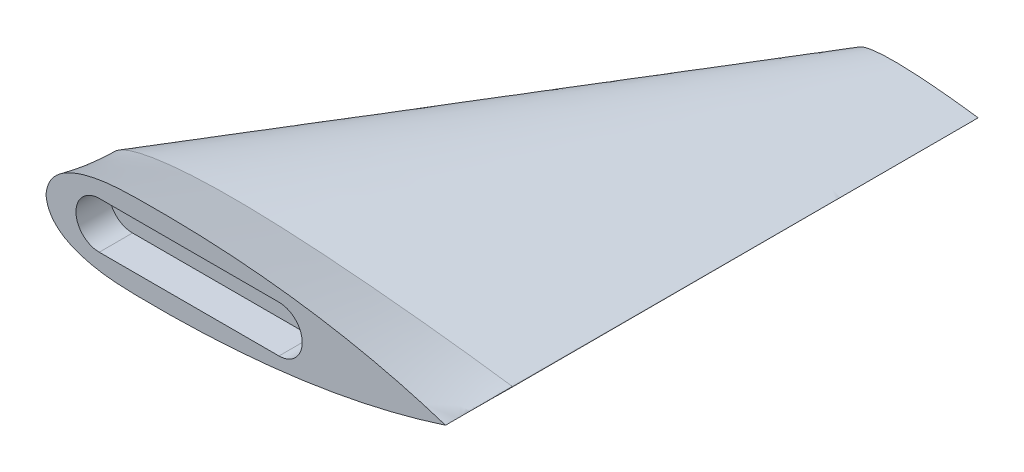
from build123d import *

# Parameters (mm, degrees)
CUT_EXTRUDE1_DEPTH = 5


with BuildPart() as part:
    # Sketch3 → Loft1 section 0
    with BuildSketch(Plane.XY.offset(70)):
        with BuildLine():
            add(Edge.make_bspline(
                [(42.022876489, 0), (42.022876489, -0.025878497), (42.030292538, -0.078965607), (42.063554444, -0.155915402), (42.117908781, -0.22997435), (42.19269573, -0.301463886), (42.287673315, -0.37063511), (42.402703243, -0.437554112), (42.537617166, -0.502144861), (42.69217588, -0.564260941), (42.866072758, -0.623717465), (43.058936641, -0.68031524), (43.270343068, -0.733841033), (43.49981216, -0.784100531), (43.74682173, -0.830887268), (44.010800762, -0.874031015), (44.291140004, -0.913354711), (44.587187402, -0.948725601), (44.898254935, -0.980017341), (45.223617257, -1.007142862), (45.562516237, -1.030039418), (45.914162375, -1.048668566), (46.27773462, -1.06303447), (46.652384122, -1.073163985), (47.037236556, -1.079112462), (47.43139403, -1.080971986), (47.833935949, -1.078853752), (48.243922409, -1.07289628), (48.660396106, -1.063260995), (49.082385456, -1.050131052), (49.508904835, -1.033698226), (49.938957981, -1.01417393), (50.371540867, -0.99177977), (50.805643888, -0.966741353), (51.240253368, -0.93929129), (51.674354334, -0.909662993), (52.106933472, -0.878089086), (52.53698035, -0.844806242), (52.963490882, -0.81003717), (53.38546826, -0.774008998), (53.801928512, -0.736940084), (54.211897782, -0.699043587), (54.614419588, -0.660532173), (55.008552494, -0.621601817), (55.393377825, -0.582454731), (55.767995156, -0.543281249), (56.131530502, -0.504273993), (56.48313406, -0.465622723), (56.821984355, -0.427500623), (57.147291331, -0.390101403), (57.458294583, -0.353598981), (57.754267715, -0.318172697), (58.034518631, -0.283997105), (58.298393967, -0.25125135), (58.54527673, -0.220100521), (58.77459078, -0.190718852), (58.9857996, -0.163257461), (59.178410588, -0.137883615), (59.351975669, -0.114738335), (59.506082658, -0.093952342), (59.640393607, -0.075694011), (59.754528952, -0.059944097), (59.848410148, -0.047189767), (59.921315664, -0.036471248), (59.974295109, -0.030390073), (60.004730475, -0.023809382), (60.035948769, -0.024404103), (60.035948769, 0.024404103), (60.004730475, 0.023809382), (59.974295109, 0.030390073), (59.921315664, 0.036471248), (59.848410148, 0.047189767), (59.754528952, 0.059944097), (59.640393607, 0.075694011), (59.506082658, 0.093952342), (59.351975669, 0.114738335), (59.178410588, 0.137883615), (58.9857996, 0.163257461), (58.77459078, 0.190718852), (58.54527673, 0.220100521), (58.298393967, 0.25125135), (58.034518631, 0.283997105), (57.754267715, 0.318172697), (57.458294583, 0.353598981), (57.147291331, 0.390101403), (56.821984355, 0.427500623), (56.48313406, 0.465622723), (56.131530502, 0.504273993), (55.767995156, 0.543281249), (55.393377825, 0.582454731), (55.008552494, 0.621601817), (54.614419588, 0.660532173), (54.211897782, 0.699043587), (53.801928512, 0.736940084), (53.38546826, 0.774008998), (52.963490882, 0.81003717), (52.53698035, 0.844806242), (52.106933472, 0.878089086), (51.674354334, 0.909662993), (51.240253368, 0.93929129), (50.805643888, 0.966741353), (50.371540867, 0.99177977), (49.938957981, 1.01417393), (49.508904835, 1.033698226), (49.082385456, 1.050131052), (48.660396106, 1.063260995), (48.243922409, 1.07289628), (47.833935949, 1.078853752), (47.43139403, 1.080971986), (47.037236556, 1.079112462), (46.652384122, 1.073163985), (46.27773462, 1.06303447), (45.914162375, 1.048668566), (45.562516237, 1.030039418), (45.223617257, 1.007142862), (44.898254935, 0.980017341), (44.587187402, 0.948725601), (44.291140004, 0.913354711), (44.010800762, 0.874031015), (43.74682173, 0.830887268), (43.49981216, 0.784100531), (43.270343068, 0.733841033), (43.058936641, 0.68031524), (42.866072758, 0.623717465), (42.69217588, 0.564260941), (42.537617166, 0.502144861), (42.402703243, 0.437554112), (42.287673315, 0.37063511), (42.19269573, 0.301463886), (42.117908781, 0.22997435), (42.063554444, 0.155915402), (42.030292538, 0.078965607), (42.022876489, 0.025878497), (42.022876489, 0)],
                knots=[0, 0, 0, 0, 0.002106168, 0.00432059, 0.006772783, 0.009556697, 0.012734041, 0.016342888, 0.020405604, 0.024934102, 0.029933071, 0.035402241, 0.04133743, 0.04773159, 0.054575389, 0.061857405, 0.069564571, 0.077682311, 0.086194684, 0.095084441, 0.104333244, 0.1139217, 0.123829339, 0.134034708, 0.144515531, 0.155248716, 0.166210356, 0.177375783, 0.188719821, 0.200216647, 0.211839951, 0.223562989, 0.235358653, 0.247199625, 0.259058395, 0.270907226, 0.282718457, 0.294464514, 0.306117689, 0.317650771, 0.329036618, 0.34024851, 0.351259999, 0.362045273, 0.372578891, 0.382836142, 0.392792739, 0.40242532, 0.411711115, 0.420628244, 0.429155673, 0.437273179, 0.444961561, 0.452202575, 0.458979063, 0.465274876, 0.471074963, 0.476365569, 0.481133961, 0.485368768, 0.489059784, 0.492198148, 0.494776266, 0.49678801, 0.498228425, 0.499094073, 0.499382862, 0.500617138, 0.500905927, 0.501771575, 0.50321199, 0.505223734, 0.507801852, 0.510940216, 0.514631232, 0.518866039, 0.523634431, 0.528925037, 0.534725124, 0.541020937, 0.547797425, 0.555038439, 0.562726821, 0.570844327, 0.579371756, 0.588288885, 0.59757468, 0.607207261, 0.617163858, 0.627421109, 0.637954727, 0.648740001, 0.65975149, 0.670963382, 0.682349229, 0.693882311, 0.705535486, 0.717281543, 0.729092774, 0.740941605, 0.752800375, 0.764641347, 0.776437011, 0.788160049, 0.799783353, 0.811280179, 0.822624217, 0.833789644, 0.844751284, 0.855484469, 0.865965292, 0.876170661, 0.8860783, 0.895666756, 0.904915559, 0.913805316, 0.922317689, 0.930435429, 0.938142595, 0.945424611, 0.95226841, 0.95866257, 0.964597759, 0.970066929, 0.975065898, 0.979594396, 0.983657112, 0.987265959, 0.990443303, 0.993227217, 0.99567941, 0.997893832, 1, 1, 1, 1], degree=3))
        make_face()
    # Sketch2 → Loft1 section 1
    with BuildSketch(Plane.XY):
        with BuildLine():
            add(Edge.make_bspline(
                [(0, 0), (0, -0.086261656), (0.024720162, -0.263218691), (0.135593184, -0.519718008), (0.316774305, -0.766581167), (0.566064137, -1.00487962), (0.882656087, -1.235450366), (1.26608918, -1.458513708), (1.715802257, -1.673816202), (2.23099797, -1.880869804), (2.81065423, -2.079058216), (3.453533838, -2.267717466), (4.158221929, -2.446136776), (4.923118902, -2.613668437), (5.746484136, -2.769624226), (6.626414244, -2.913436716), (7.560878382, -3.044515703), (8.547703041, -3.162418671), (9.584594818, -3.266724471), (10.669135892, -3.357142873), (11.798799161, -3.433464726), (12.970952952, -3.495561888), (14.182860437, -3.543448233), (15.43169211, -3.577213282), (16.714533557, -3.597041539), (18.028391802, -3.603239953), (19.370198199, -3.596179173), (20.736819734, -3.576320934), (22.125065389, -3.544203316), (23.531696556, -3.50043684), (24.953427821, -3.445660752), (26.386938306, -3.380579767), (27.82888126, -3.305932568), (29.27589133, -3.222471175), (30.724589596, -3.130970966), (32.171592815, -3.032209976), (33.613523275, -2.926963621), (35.04701287, -2.816020806), (36.468714641, -2.700123901), (37.875305901, -2.580029992), (39.263506742, -2.456466948), (40.630070975, -2.330145291), (41.971810329, -2.201773909), (43.285586683, -2.072006057), (44.568337784, -1.94151577), (45.817062224, -1.810937497), (47.028846709, -1.680913309), (48.20085857, -1.552075743), (49.330359552, -1.425002076), (50.414716139, -1.300338011), (51.451393648, -1.17866327), (52.437970753, -1.060575655), (53.372140472, -0.946657018), (54.251724925, -0.837504499), (55.07466747, -0.733668403), (55.839047636, -0.635729508), (56.543077037, -0.544191538), (57.185113664, -0.459612051), (57.763663931, -0.382461118), (58.277353896, -0.313174474), (58.72505706, -0.252313371), (59.105508208, -0.199813656), (59.418445528, -0.157299223), (59.661463916, -0.121570828), (59.838062067, -0.101300242), (59.939513285, -0.079364607), (60.043574265, -0.081347009), (60.043574265, 0.081347009), (59.939513285, 0.079364607), (59.838062067, 0.101300242), (59.661463916, 0.121570828), (59.418445528, 0.157299223), (59.105508208, 0.199813656), (58.72505706, 0.252313371), (58.277353896, 0.313174474), (57.763663931, 0.382461118), (57.185113664, 0.459612051), (56.543077037, 0.544191538), (55.839047636, 0.635729508), (55.07466747, 0.733668403), (54.251724925, 0.837504499), (53.372140472, 0.946657018), (52.437970753, 1.060575655), (51.451393648, 1.17866327), (50.414716139, 1.300338011), (49.330359552, 1.425002076), (48.20085857, 1.552075743), (47.028846709, 1.680913309), (45.817062224, 1.810937497), (44.568337784, 1.94151577), (43.285586683, 2.072006057), (41.971810329, 2.201773909), (40.630070975, 2.330145291), (39.263506742, 2.456466948), (37.875305901, 2.580029992), (36.468714641, 2.700123901), (35.04701287, 2.816020806), (33.613523275, 2.926963621), (32.171592815, 3.032209976), (30.724589596, 3.130970966), (29.27589133, 3.222471175), (27.82888126, 3.305932568), (26.386938306, 3.380579767), (24.953427821, 3.445660752), (23.531696556, 3.50043684), (22.125065389, 3.544203316), (20.736819734, 3.576320934), (19.370198199, 3.596179173), (18.028391802, 3.603239953), (16.714533557, 3.597041539), (15.43169211, 3.577213282), (14.182860437, 3.543448233), (12.970952952, 3.495561888), (11.798799161, 3.433464726), (10.669135892, 3.357142873), (9.584594818, 3.266724471), (8.547703041, 3.162418671), (7.560878382, 3.044515703), (6.626414244, 2.913436716), (5.746484136, 2.769624226), (4.923118902, 2.613668437), (4.158221929, 2.446136776), (3.453533838, 2.267717466), (2.81065423, 2.079058216), (2.23099797, 1.880869804), (1.715802257, 1.673816202), (1.26608918, 1.458513708), (0.882656087, 1.235450366), (0.566064137, 1.00487962), (0.316774305, 0.766581167), (0.135593184, 0.519718008), (0.024720162, 0.263218691), (0, 0.086261656), (0, 0)],
                knots=[0, 0, 0, 0, 0.002106168, 0.00432059, 0.006772783, 0.009556697, 0.012734041, 0.016342888, 0.020405604, 0.024934102, 0.029933071, 0.035402241, 0.04133743, 0.04773159, 0.054575389, 0.061857405, 0.069564571, 0.077682311, 0.086194684, 0.095084441, 0.104333244, 0.1139217, 0.123829339, 0.134034708, 0.144515531, 0.155248716, 0.166210356, 0.177375783, 0.188719821, 0.200216647, 0.211839951, 0.223562989, 0.235358653, 0.247199625, 0.259058395, 0.270907226, 0.282718457, 0.294464514, 0.306117689, 0.317650771, 0.329036618, 0.34024851, 0.351259999, 0.362045273, 0.372578891, 0.382836142, 0.392792739, 0.40242532, 0.411711115, 0.420628244, 0.429155673, 0.437273179, 0.444961561, 0.452202575, 0.458979063, 0.465274876, 0.471074963, 0.476365569, 0.481133961, 0.485368768, 0.489059784, 0.492198148, 0.494776266, 0.49678801, 0.498228425, 0.499094073, 0.499382862, 0.500617138, 0.500905927, 0.501771575, 0.50321199, 0.505223734, 0.507801852, 0.510940216, 0.514631232, 0.518866039, 0.523634431, 0.528925037, 0.534725124, 0.541020937, 0.547797425, 0.555038439, 0.562726821, 0.570844327, 0.579371756, 0.588288885, 0.59757468, 0.607207261, 0.617163858, 0.627421109, 0.637954727, 0.648740001, 0.65975149, 0.670963382, 0.682349229, 0.693882311, 0.705535486, 0.717281543, 0.729092774, 0.740941605, 0.752800375, 0.764641347, 0.776437011, 0.788160049, 0.799783353, 0.811280179, 0.822624217, 0.833789644, 0.844751284, 0.855484469, 0.865965292, 0.876170661, 0.8860783, 0.895666756, 0.904915559, 0.913805316, 0.922317689, 0.930435429, 0.938142595, 0.945424611, 0.95226841, 0.95866257, 0.964597759, 0.970066929, 0.975065898, 0.979594396, 0.983657112, 0.987265959, 0.990443303, 0.993227217, 0.99567941, 0.997893832, 1, 1, 1, 1], degree=3))
        make_face()
    loft()

    # Sketch8 → Loft2 section 0
    with BuildSketch(Plane(origin=(0, 0, -10), x_dir=(-1, 0, 0), z_dir=(0, 0, -1))):
        with BuildLine():
            add(Edge.make_bspline(
                [(-60.032680699, 0), (-45.229186862, 4.822427248), (-26.687327325, 6.871056485), (-5.794980295, 6.092943746), (-0.269324366, 3.253888107), (0, 0)],
                knots=[0, 0, 0, 0, 0.73900426, 0.864029196, 1, 1, 1, 1], degree=3))
            add(Edge.make_bspline(
                [(-60.032680699, 0), (-45.229186862, -4.822427248), (-26.687327325, -6.871056485), (-5.794980295, -6.092943746), (-0.269324366, -3.253888107), (0, 0)],
                knots=[0, 0, 0, 0, 0.73900426, 0.864029196, 1, 1, 1, 1], degree=3))
        make_face()
    # Sketch2_3 → Loft2 section 1
    with BuildSketch(Plane.XY):
        with BuildLine():
            add(Edge.make_bspline(
                [(0, 0), (0, -0.086261656), (0.024720162, -0.263218691), (0.135593184, -0.519718008), (0.316774305, -0.766581167), (0.566064137, -1.00487962), (0.882656087, -1.235450366), (1.26608918, -1.458513708), (1.715802257, -1.673816202), (2.23099797, -1.880869804), (2.81065423, -2.079058216), (3.453533838, -2.267717466), (4.158221929, -2.446136776), (4.923118902, -2.613668437), (5.746484136, -2.769624226), (6.626414244, -2.913436716), (7.560878382, -3.044515703), (8.547703041, -3.162418671), (9.584594818, -3.266724471), (10.669135892, -3.357142873), (11.798799161, -3.433464726), (12.970952952, -3.495561888), (14.182860437, -3.543448233), (15.43169211, -3.577213282), (16.714533557, -3.597041539), (18.028391802, -3.603239953), (19.370198199, -3.596179173), (20.736819734, -3.576320934), (22.125065389, -3.544203316), (23.531696556, -3.50043684), (24.953427821, -3.445660752), (26.386938306, -3.380579767), (27.82888126, -3.305932568), (29.27589133, -3.222471175), (30.724589596, -3.130970966), (32.171592815, -3.032209976), (33.613523275, -2.926963621), (35.04701287, -2.816020806), (36.468714641, -2.700123901), (37.875305901, -2.580029992), (39.263506742, -2.456466948), (40.630070975, -2.330145291), (41.971810329, -2.201773909), (43.285586683, -2.072006057), (44.568337784, -1.94151577), (45.817062224, -1.810937497), (47.028846709, -1.680913309), (48.20085857, -1.552075743), (49.330359552, -1.425002076), (50.414716139, -1.300338011), (51.451393648, -1.17866327), (52.437970753, -1.060575655), (53.372140472, -0.946657018), (54.251724925, -0.837504499), (55.07466747, -0.733668403), (55.839047636, -0.635729508), (56.543077037, -0.544191538), (57.185113664, -0.459612051), (57.763663931, -0.382461118), (58.277353896, -0.313174474), (58.72505706, -0.252313371), (59.105508208, -0.199813656), (59.418445528, -0.157299223), (59.661463916, -0.121570828), (59.838062067, -0.101300242), (59.939513285, -0.079364607), (60.043574265, -0.081347009), (60.043574265, 0.081347009), (59.939513285, 0.079364607), (59.838062067, 0.101300242), (59.661463916, 0.121570828), (59.418445528, 0.157299223), (59.105508208, 0.199813656), (58.72505706, 0.252313371), (58.277353896, 0.313174474), (57.763663931, 0.382461118), (57.185113664, 0.459612051), (56.543077037, 0.544191538), (55.839047636, 0.635729508), (55.07466747, 0.733668403), (54.251724925, 0.837504499), (53.372140472, 0.946657018), (52.437970753, 1.060575655), (51.451393648, 1.17866327), (50.414716139, 1.300338011), (49.330359552, 1.425002076), (48.20085857, 1.552075743), (47.028846709, 1.680913309), (45.817062224, 1.810937497), (44.568337784, 1.94151577), (43.285586683, 2.072006057), (41.971810329, 2.201773909), (40.630070975, 2.330145291), (39.263506742, 2.456466948), (37.875305901, 2.580029992), (36.468714641, 2.700123901), (35.04701287, 2.816020806), (33.613523275, 2.926963621), (32.171592815, 3.032209976), (30.724589596, 3.130970966), (29.27589133, 3.222471175), (27.82888126, 3.305932568), (26.386938306, 3.380579767), (24.953427821, 3.445660752), (23.531696556, 3.50043684), (22.125065389, 3.544203316), (20.736819734, 3.576320934), (19.370198199, 3.596179173), (18.028391802, 3.603239953), (16.714533557, 3.597041539), (15.43169211, 3.577213282), (14.182860437, 3.543448233), (12.970952952, 3.495561888), (11.798799161, 3.433464726), (10.669135892, 3.357142873), (9.584594818, 3.266724471), (8.547703041, 3.162418671), (7.560878382, 3.044515703), (6.626414244, 2.913436716), (5.746484136, 2.769624226), (4.923118902, 2.613668437), (4.158221929, 2.446136776), (3.453533838, 2.267717466), (2.81065423, 2.079058216), (2.23099797, 1.880869804), (1.715802257, 1.673816202), (1.26608918, 1.458513708), (0.882656087, 1.235450366), (0.566064137, 1.00487962), (0.316774305, 0.766581167), (0.135593184, 0.519718008), (0.024720162, 0.263218691), (0, 0.086261656), (0, 0)],
                knots=[0, 0, 0, 0, 0.002106168, 0.00432059, 0.006772783, 0.009556697, 0.012734041, 0.016342888, 0.020405604, 0.024934102, 0.029933071, 0.035402241, 0.04133743, 0.04773159, 0.054575389, 0.061857405, 0.069564571, 0.077682311, 0.086194684, 0.095084441, 0.104333244, 0.1139217, 0.123829339, 0.134034708, 0.144515531, 0.155248716, 0.166210356, 0.177375783, 0.188719821, 0.200216647, 0.211839951, 0.223562989, 0.235358653, 0.247199625, 0.259058395, 0.270907226, 0.282718457, 0.294464514, 0.306117689, 0.317650771, 0.329036618, 0.34024851, 0.351259999, 0.362045273, 0.372578891, 0.382836142, 0.392792739, 0.40242532, 0.411711115, 0.420628244, 0.429155673, 0.437273179, 0.444961561, 0.452202575, 0.458979063, 0.465274876, 0.471074963, 0.476365569, 0.481133961, 0.485368768, 0.489059784, 0.492198148, 0.494776266, 0.49678801, 0.498228425, 0.499094073, 0.499382862, 0.500617138, 0.500905927, 0.501771575, 0.50321199, 0.505223734, 0.507801852, 0.510940216, 0.514631232, 0.518866039, 0.523634431, 0.528925037, 0.534725124, 0.541020937, 0.547797425, 0.555038439, 0.562726821, 0.570844327, 0.579371756, 0.588288885, 0.59757468, 0.607207261, 0.617163858, 0.627421109, 0.637954727, 0.648740001, 0.65975149, 0.670963382, 0.682349229, 0.693882311, 0.705535486, 0.717281543, 0.729092774, 0.740941605, 0.752800375, 0.764641347, 0.776437011, 0.788160049, 0.799783353, 0.811280179, 0.822624217, 0.833789644, 0.844751284, 0.855484469, 0.865965292, 0.876170661, 0.8860783, 0.895666756, 0.904915559, 0.913805316, 0.922317689, 0.930435429, 0.938142595, 0.945424611, 0.95226841, 0.95866257, 0.964597759, 0.970066929, 0.975065898, 0.979594396, 0.983657112, 0.987265959, 0.990443303, 0.993227217, 0.99567941, 0.997893832, 1, 1, 1, 1], degree=3))
        make_face()
    loft()

    # Sketch9 → Cut-Extrude1 (cut)
    with BuildSketch(Plane(origin=(0, 0, -10), x_dir=(-1, 0, 0), z_dir=(0, 0, -1))):
        with BuildLine():
            Line((-35, 3.5), (-8, 3.5))
            ThreePointArc((-8, 3.5), (-4.5, 0), (-8, -3.5))
            Line((-8, -3.5), (-35, -3.5))
            ThreePointArc((-35, -3.5), (-38.5, 0), (-35, 3.5))
        make_face()
    extrude(amount=-CUT_EXTRUDE1_DEPTH, mode=Mode.SUBTRACT)


with BuildPart() as body_2:
    # Mirror1: mirrored copy
    add(part.part.mirror(Plane(origin=(28.97377947, -5.906413291, -10), x_dir=(1, 0, 0), z_dir=(0, 0, 1))))


solid = body_2.part
